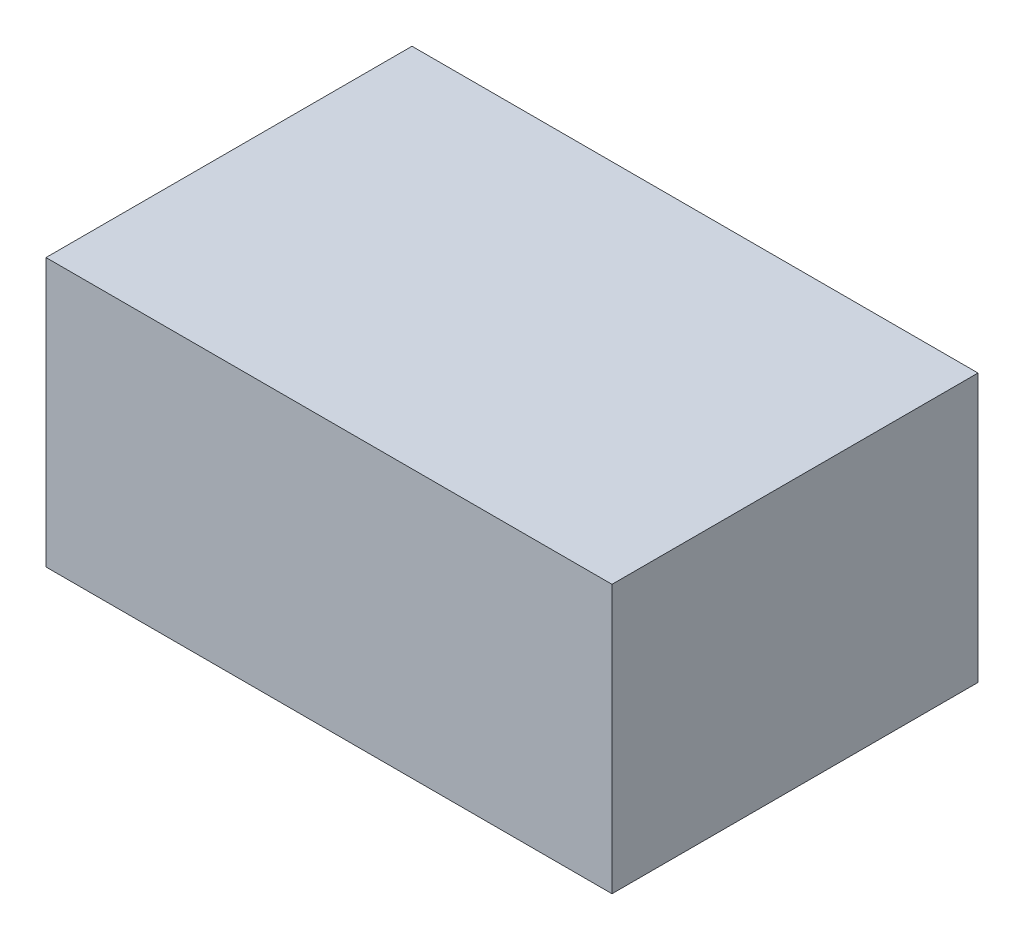
from build123d import *

# Parameters (mm, degrees)
SKETCH1_W           = 71.882
SKETCH1_H           = 34.036
BOSS_EXTRUDE1_DEPTH = 46.482


with BuildPart() as part:
    # Sketch1 → Boss-Extrude1 (new body)
    with BuildSketch(Plane.XY):
        with Locations((35.941, 17.018)):
            Rectangle(SKETCH1_W, SKETCH1_H)
    extrude(amount=BOSS_EXTRUDE1_DEPTH)


solid = part.part
